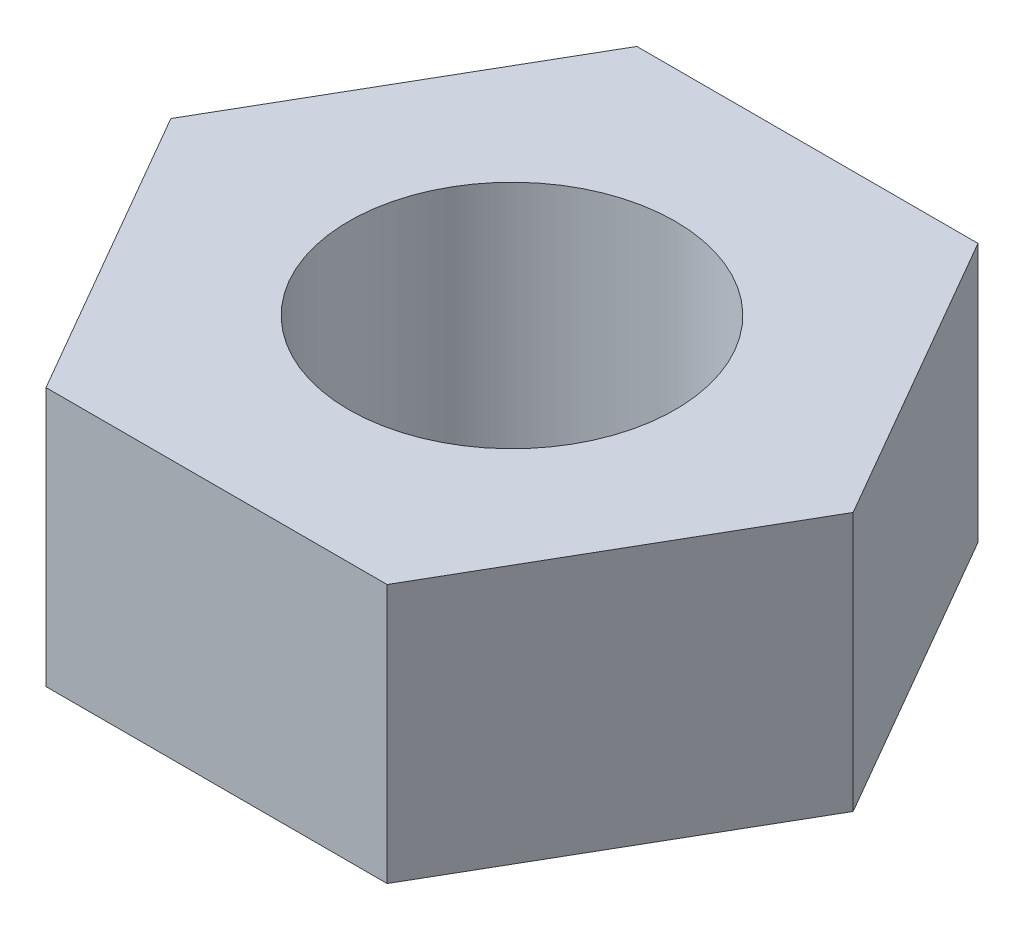
from build123d import *

# Parameters (mm, degrees)
SKETCH1_R           = 1.5
BOSS_EXTRUDE1_DEPTH = 2.38


with BuildPart() as part:
    # Sketch1 → Boss-Extrude1 (new body)
    with BuildSketch(Plane(origin=(0, 0, 0), x_dir=(1, 0, 0), z_dir=(0, 1, 0))):
        Polygon((3.135011962, 0), (1.567505981, 2.715), (-1.567505981, 2.715), (-3.135011962, 0), (-1.567505981, -2.715), (1.567505981, -2.715), align=None)
        Circle(SKETCH1_R, mode=Mode.SUBTRACT)
    extrude(amount=BOSS_EXTRUDE1_DEPTH)


solid = part.part
